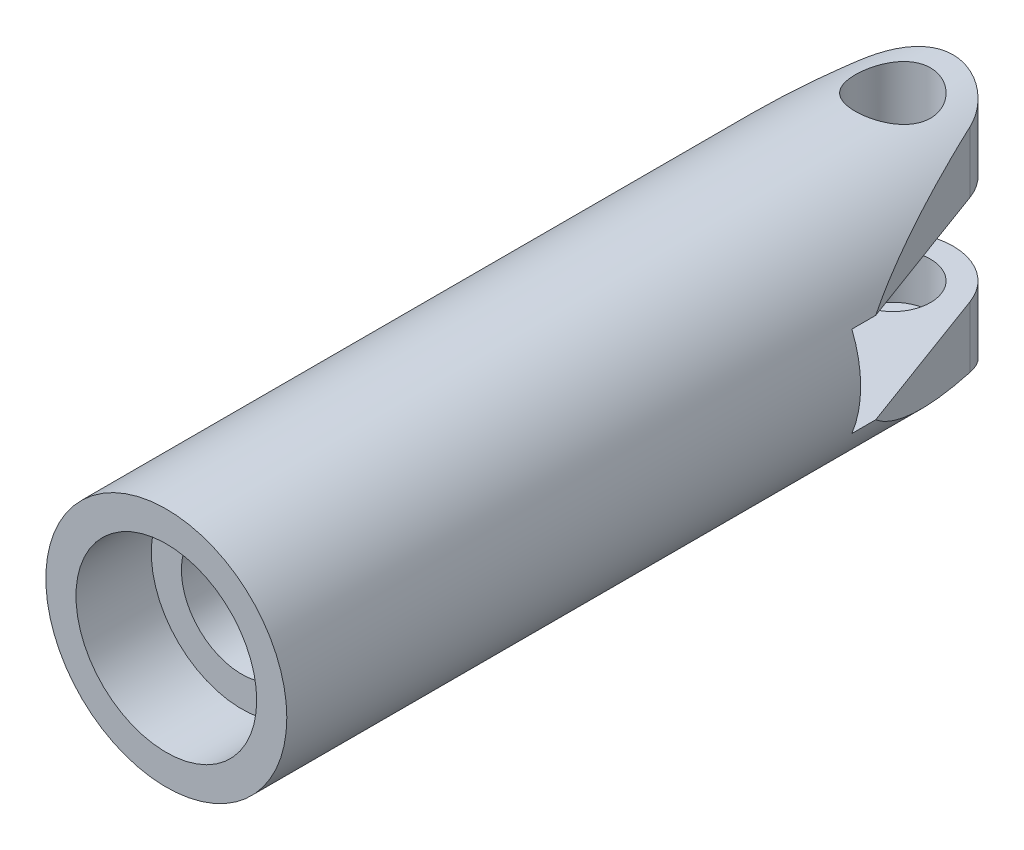
from build123d import *

# Parameters (mm, degrees)
CUT_EXTRUDE2_DEPTH      = 40.744307769
CUT_EXTRUDE2_DEPTH_BACK = 40.744307769
SKETCH4_W               = 25.011127608
SKETCH4_H               = 6
CUT_EXTRUDE3_DEPTH      = 40.744307905
CUT_EXTRUDE3_DEPTH_BACK = 40.744307905
SKETCH3_4_R             = 2.5
CUT_EXTRUDE4_DEPTH      = 40.744307905
CUT_EXTRUDE4_DEPTH_BACK = 6


with BuildPart() as part:
    # Sketch2 → Revolve1 (revolve)
    with BuildSketch(Plane(origin=(0, 0, 0), x_dir=(0, 0, -1), z_dir=(1, 0, 0)), mode=Mode.PRIVATE) as revolve1_sk:
        Polygon((-33.1, 4), (0, 4), (0, 3), (20, 3), (20, 8), (-38.1, 8), (-38.1, 6), (-33.1, 6), align=None)
    revolve(revolve1_sk.sketch.rotate(Axis((0, 0, 12.975169934), (0, 0, -1)), 90), axis=Axis((0, 0, 12.975169934), (0, 0, -1)))

    # Sketch3 → Cut-Extrude2 (cut, two sides)
    with BuildSketch(Plane(origin=(0, 0, 0), x_dir=(1, 0, 0), z_dir=(0, 1, 0))) as cut_extrude2_sk:
        with BuildLine():
            Line((8, 0), (8, 25))
            Line((8, 25), (-8, 25))
            Line((-8, 25), (-8, 0))
            Line((-8, 0), (-3.753065966, 11.519523043))
            ThreePointArc((-3.753065966, 11.519523043), (0, 14.13586996), (3.753065966, 11.519523043))
            Line((3.753065966, 11.519523043), (8, 0))
        make_face()
    extrude(amount=CUT_EXTRUDE2_DEPTH, mode=Mode.SUBTRACT)
    extrude(cut_extrude2_sk.sketch, amount=-CUT_EXTRUDE2_DEPTH_BACK, mode=Mode.SUBTRACT)

    # Sketch4 → Cut-Extrude3 (cut, two sides)
    with BuildSketch(Plane(origin=(0, 0, 0), x_dir=(0, 0, -1), z_dir=(1, 0, 0))) as cut_extrude3_sk:
        with Locations((12.505563804, 0)):
            Rectangle(SKETCH4_W, SKETCH4_H)
    extrude(amount=CUT_EXTRUDE3_DEPTH, mode=Mode.SUBTRACT)
    extrude(cut_extrude3_sk.sketch, amount=-CUT_EXTRUDE3_DEPTH_BACK, mode=Mode.SUBTRACT)

    # Sketch3_4 → Cut-Extrude4 (cut, two sides)
    with BuildSketch(Plane(origin=(0, 0, 0), x_dir=(1, 0, 0), z_dir=(0, 1, 0))) as cut_extrude4_sk:
        with Locations(Location((0, 10.13586996, 0), (0, 0, 270))):
            Circle(SKETCH3_4_R)
    extrude(amount=CUT_EXTRUDE4_DEPTH, mode=Mode.SUBTRACT)
    extrude(cut_extrude4_sk.sketch, amount=-CUT_EXTRUDE4_DEPTH_BACK, mode=Mode.SUBTRACT)


solid = part.part
